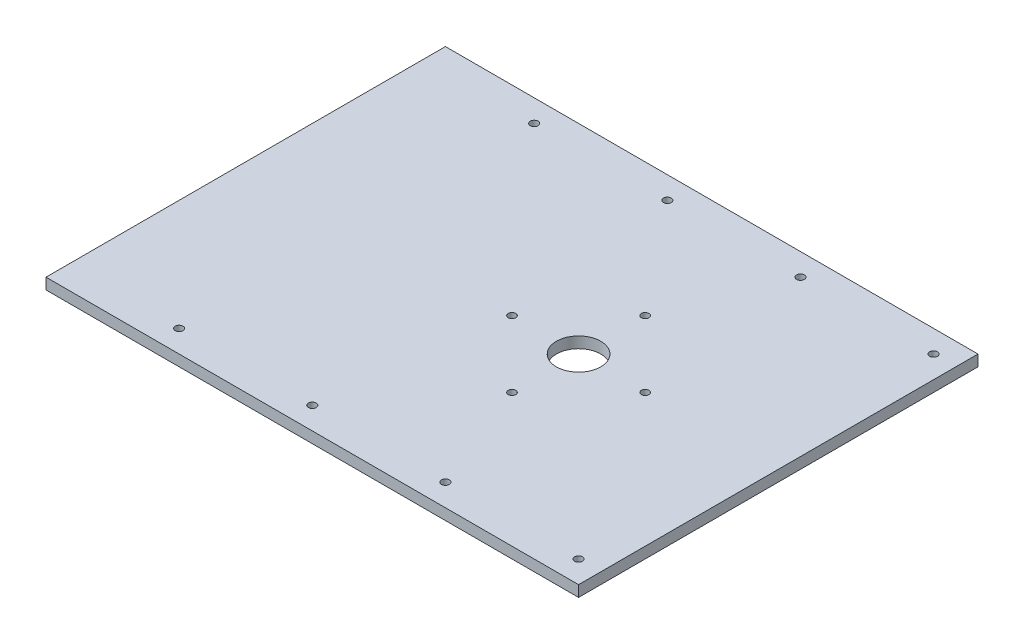
from build123d import *

# Parameters (mm, degrees)
SKETCH1_W                                         = 304.8
SKETCH1_H                                         = 228.6
BOSS_EXTRUDE1_DEPTH                               = 6.35
CSK_FOR_8_FLAT_HEAD_MACHINE_SCREW_100_D           = 4.3053
CSK_FOR_8_FLAT_HEAD_MACHINE_SCREW_100_CSINK_D     = 8.4328
CSK_FOR_8_FLAT_HEAD_MACHINE_SCREW_100_CSINK_ANGLE = 100
CIRPATTERN1_COUNT                                 = 4
SKETCH5_R                                         = 12.7
CUT_EXTRUDE1_DEPTH                                = 7.35
CSK_FOR_8_FLAT_HEAD_MACHINE_SCREW_2_D             = 4.4958
CSK_FOR_8_FLAT_HEAD_MACHINE_SCREW_2_CSINK_D       = 8.4328
CSK_FOR_8_FLAT_HEAD_MACHINE_SCREW_2_CSINK_ANGLE   = 100
LPATTERN1_COUNT                                   = 4
LPATTERN1_PITCH                                   = 76.2


with BuildPart() as part:
    # Sketch1 → Boss-Extrude1 (new body)
    with BuildSketch(Plane(origin=(0, 0, 0), x_dir=(1, 0, 0), z_dir=(0, 1, 0))):
        with Locations((-152.4, 114.3)):
            Rectangle(SKETCH1_W, SKETCH1_H)
    extrude(amount=BOSS_EXTRUDE1_DEPTH)

    # CSK for _8 Flat Head Machine Screw _100 (through all)
    with Locations(Plane.XZ):
        with Locations((-114.3, -76.2)):
            csk_for_8_flat_head_machine_screw_100 = CounterSinkHole(CSK_FOR_8_FLAT_HEAD_MACHINE_SCREW_100_D / 2, CSK_FOR_8_FLAT_HEAD_MACHINE_SCREW_100_CSINK_D / 2, counter_sink_angle=CSK_FOR_8_FLAT_HEAD_MACHINE_SCREW_100_CSINK_ANGLE)

    # CirPattern1: CSK for _8 Flat Head Machine Screw _100 ×4 about axis
    cirpattern1_axis = Axis((-114.3, 0, -114.3), (0, 1, 0))
    for i in range(1, CIRPATTERN1_COUNT):
        add(csk_for_8_flat_head_machine_screw_100.rotate(cirpattern1_axis, i * 360 / CIRPATTERN1_COUNT), mode=Mode.SUBTRACT)

    # Sketch5 → Cut-Extrude1 (cut, through all)
    with BuildSketch(Plane(origin=(0, 6.35, 0), x_dir=(-1, 0, 0), z_dir=(0, 1, 0))):
        with Locations(Location((114.3, -114.3, 0), (0, 0, 90))):  # turned: the seam where the file's is
            Circle(SKETCH5_R)
    extrude(amount=-CUT_EXTRUDE1_DEPTH, mode=Mode.SUBTRACT)

    # CSK for _8 Flat Head Machine Screw _ 2 (through all)
    with Locations(Plane.XZ):
        with Locations((-12.7, -12.7), (-12.7, -215.9)):
            csk_for_8_flat_head_machine_screw_2 = CounterSinkHole(CSK_FOR_8_FLAT_HEAD_MACHINE_SCREW_2_D / 2, CSK_FOR_8_FLAT_HEAD_MACHINE_SCREW_2_CSINK_D / 2, counter_sink_angle=CSK_FOR_8_FLAT_HEAD_MACHINE_SCREW_2_CSINK_ANGLE)

    # LPattern1: CSK for _8 Flat Head Machine Screw _ 2 ×4
    with Locations(*[(-i * LPATTERN1_PITCH, 0, 0) for i in range(1, LPATTERN1_COUNT)]):
        add(csk_for_8_flat_head_machine_screw_2, mode=Mode.SUBTRACT)


solid = part.part
